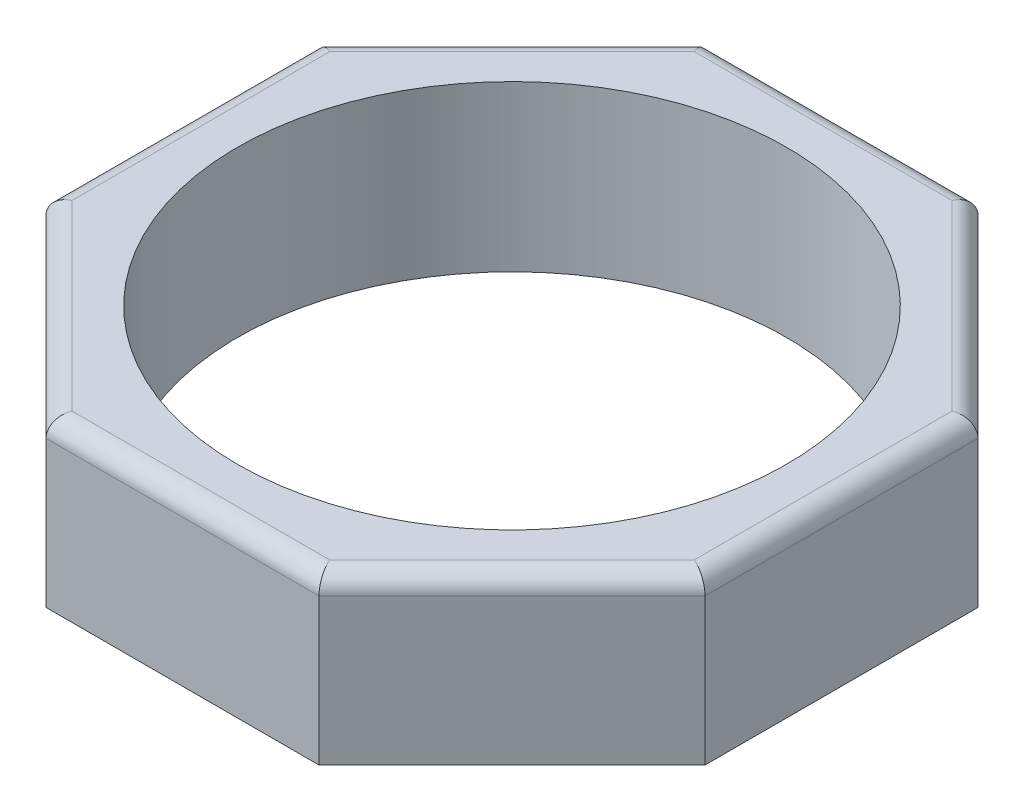
from build123d import *

# Parameters (mm, degrees)
SALIENTE_EXTRUIR1_DEPTH = 9
CROQUIS2_R              = 15
CORTAR_EXTRUIR1_DEPTH   = 10
REDONDEO1_R             = 1


with BuildPart() as part:
    # Croquis1 → Saliente-Extruir1 (new body)
    with BuildSketch(Plane(origin=(0, 0, 0), x_dir=(1, 0, 0), z_dir=(0, 1, 0))):
        Polygon((18, 7.455844123), (7.455844123, 18), (-7.455844123, 18), (-18, 7.455844123), (-18, -7.455844123), (-7.455844123, -18), (7.455844123, -18), (18, -7.455844123), align=None)
    extrude(amount=SALIENTE_EXTRUIR1_DEPTH)

    # Croquis2 → Cortar-Extruir1 (cut, through all)
    with BuildSketch(Plane(origin=(0, 9, 0), x_dir=(1, 0, 0), z_dir=(0, 1, 0))):
        Circle(CROQUIS2_R)
    extrude(amount=-CORTAR_EXTRUIR1_DEPTH, mode=Mode.SUBTRACT)

    # Redondeo1
    redondeo1_edges = [part.edges().sort_by_distance(p)[0] for p in [
        (0, 9, -18),
        (-12.727922061, 9, -12.727922061),
        (-18, 9, 0),
        (-12.727922061, 9, 12.727922061),
        (0, 9, 18),
        (12.727922061, 9, 12.727922061),
        (18, 9, 0),
        (12.727922061, 9, -12.727922061),
    ]]
    fillet(redondeo1_edges, radius=REDONDEO1_R)


solid = part.part
